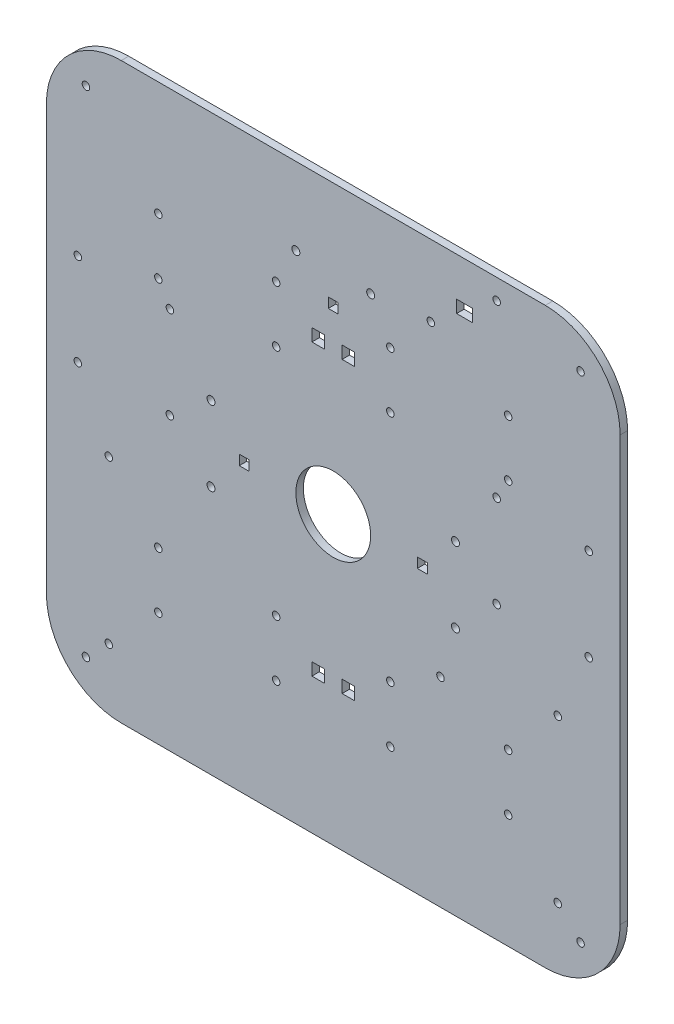
from build123d import *

# Parameters (mm, degrees)
CROQUIS1_W              = 230
CROQUIS1_H              = 230
SALIENTE_EXTRUIR2_DEPTH = 3
REDONDEO1_R             = 30
REDONDEO2_R             = 30
REDONDEO3_R             = 30
REDONDEO4_R             = 30
CROQUIS2_R              = 1.5
CROQUIS2_R_2            = 15
CROQUIS2_R_3            = 1.6
CROQUIS2_W              = 5
CROQUIS2_H              = 5
CROQUIS2_W_2            = 4
CROQUIS2_H_2            = 4
CROQUIS2_W_3            = 6.425619835
CORTAR_EXTRUIR2_DEPTH   = 3


with BuildPart() as part:
    # Croquis1 → Saliente-Extruir2 (new body)
    with BuildSketch(Plane.XY):
        Rectangle(CROQUIS1_W, CROQUIS1_H)
    extrude(amount=SALIENTE_EXTRUIR2_DEPTH)

    # Redondeo1
    redondeo1_edges = [part.edges().sort_by_distance(p)[0] for p in [
        (-115, 115, 1.5),
    ]]
    fillet(redondeo1_edges, radius=REDONDEO1_R)

    # Redondeo2
    redondeo2_edges = [part.edges().sort_by_distance(p)[0] for p in [
        (-115, -115, 1.5),
    ]]
    fillet(redondeo2_edges, radius=REDONDEO2_R)

    # Redondeo3
    redondeo3_edges = [part.edges().sort_by_distance(p)[0] for p in [
        (115, -115, 1.5),
    ]]
    fillet(redondeo3_edges, radius=REDONDEO3_R)

    # Redondeo4
    redondeo4_edges = [part.edges().sort_by_distance(p)[0] for p in [
        (115, 115, 1.5),
    ]]
    fillet(redondeo4_edges, radius=REDONDEO4_R)

    # Croquis2 → Cortar-Extruir2 (cut)
    with BuildSketch(Plane.XY.offset(3)):
        with Locations((-22.88, 46.75)):
            Circle(CROQUIS2_R)
        with Locations((-70.13, 46.75)):
            Circle(CROQUIS2_R)
        with Locations((-70.13, 69.25)):
            Circle(CROQUIS2_R)
        with Locations((-22.88, 69.25)):
            Circle(CROQUIS2_R)
        with Locations((22.88, 69.25)):
            Circle(CROQUIS2_R)
        with Locations((22.88, 46.75)):
            Circle(CROQUIS2_R)
        with Locations((70.13, 46.75)):
            Circle(CROQUIS2_R)
        with Locations((70.13, 69.25)):
            Circle(CROQUIS2_R)
        with Locations((70.13, -69.25)):
            Circle(CROQUIS2_R)
        with Locations((70.13, -46.75)):
            Circle(CROQUIS2_R)
        with Locations((22.88, -69.25)):
            Circle(CROQUIS2_R)
        with Locations((22.88, -46.75)):
            Circle(CROQUIS2_R)
        with Locations((-22.88, -46.75)):
            Circle(CROQUIS2_R)
        with Locations((-22.88, -69.25)):
            Circle(CROQUIS2_R)
        with Locations((-70.13, -69.25)):
            Circle(CROQUIS2_R)
        with Locations((-70.13, -46.75)):
            Circle(CROQUIS2_R)
        Circle(CROQUIS2_R_2)
        with Locations((42.973295778, -34.981331753)):
            Circle(CROQUIS2_R)
        with Locations((-99.142135624, 99.142135624)):
            Circle(CROQUIS2_R)
        with Locations((99.142135624, 99.142135624)):
            Circle(CROQUIS2_R)
        with Locations((99.142135624, -99.142135624)):
            Circle(CROQUIS2_R)
        with Locations((-99.142135624, -99.142135624)):
            Circle(CROQUIS2_R)
        with Locations((-49, 15)):
            Circle(CROQUIS2_R_3)
        with Locations((-49, -15)):
            Circle(CROQUIS2_R_3)
        with Locations((49, 15)):
            Circle(CROQUIS2_R_3)
        with Locations((49, -15)):
            Circle(CROQUIS2_R_3)
        with Locations((15, 84)):
            Circle(CROQUIS2_R_3)
        with Locations((-15, 84)):
            Circle(CROQUIS2_R_3)
        with Locations((-102.407537284, 38.45)):
            Circle(CROQUIS2_R)
        with Locations((-65.507537284, 38.45)):
            Circle(CROQUIS2_R)
        with Locations((-65.507537284, 1.55)):
            Circle(CROQUIS2_R)
        with Locations((-102.407537284, 1.55)):
            Circle(CROQUIS2_R)
        with Locations((102.407537284, 1.55)):
            Circle(CROQUIS2_R)
        with Locations((65.507537284, 1.55)):
            Circle(CROQUIS2_R)
        with Locations((65.507537284, 38.45)):
            Circle(CROQUIS2_R)
        with Locations((102.407537284, 38.45)):
            Circle(CROQUIS2_R)
        with Locations((-90, -90)):
            Circle(CROQUIS2_R)
        with Locations((90, -90)):
            Circle(CROQUIS2_R)
        with Locations((90, -25)):
            Circle(CROQUIS2_R)
        with Locations((-90, -25)):
            Circle(CROQUIS2_R)
        with Locations((39.09562129, 86.314599105)):
            Circle(CROQUIS2_R)
        with Locations((65.507537284, 106.866636631)):
            Circle(CROQUIS2_R)
        with Locations((-6.05453105, 58.000440639)):
            Rectangle(CROQUIS2_W, CROQUIS2_H)
        with Locations((6.05453105, 58.000440639)):
            Rectangle(CROQUIS2_W, CROQUIS2_H)
        with Locations((6.05453105, -58.000440639)):
            Rectangle(CROQUIS2_W, CROQUIS2_H)
        with Locations((-6.05453105, -58.000440639)):
            Rectangle(CROQUIS2_W, CROQUIS2_H)
        with Locations((35.684074381, 0)):
            Rectangle(CROQUIS2_W_2, CROQUIS2_H_2)
        with Locations((0, 72.426144441)):
            Rectangle(CROQUIS2_W_2, CROQUIS2_H_2)
        with Locations((-35.684074381, 0)):
            Rectangle(CROQUIS2_W_2, CROQUIS2_H_2)
        with Locations((52.672582405, 96.879308397)):
            Rectangle(CROQUIS2_W_3, CROQUIS2_H)
    extrude(amount=-CORTAR_EXTRUIR2_DEPTH, mode=Mode.SUBTRACT)


solid = part.part
